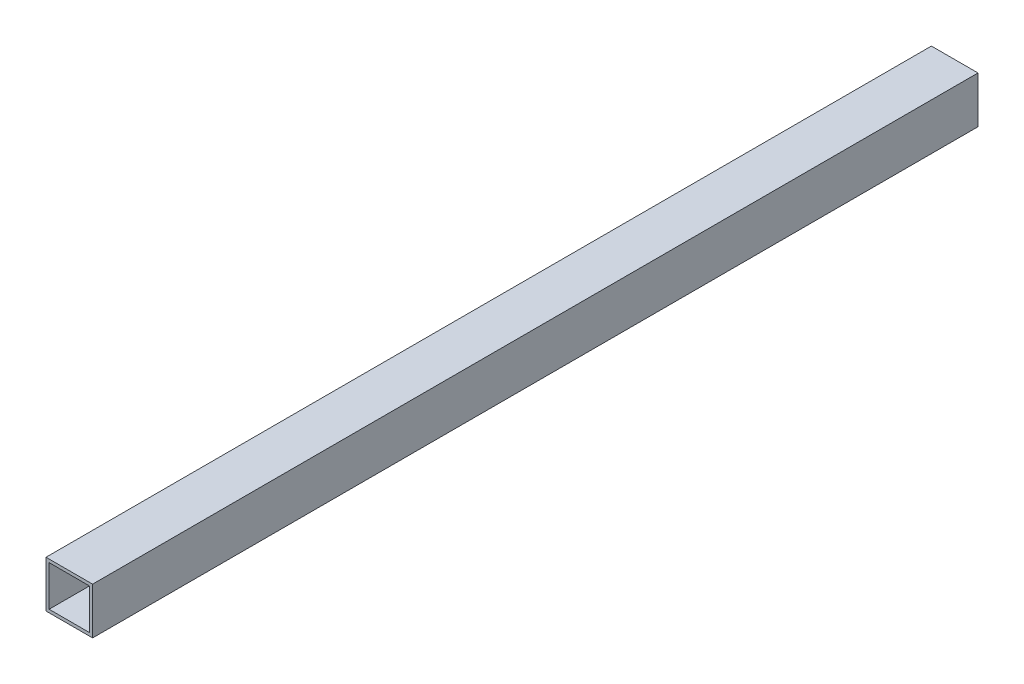
from build123d import *

# Parameters (mm, degrees)
ESBO_O2_W                = 30
ESBO_O2_H                = 30
RESSALTO_EXTRUS_O1_DEPTH = 570
CASCA2_T                 = -2


with BuildPart() as part:
    # Esboço2 → Ressalto-extrusão1 (new body)
    with BuildSketch(Plane.XY):
        with Locations((-79.205213928, 44.662246879)):
            Rectangle(ESBO_O2_W, ESBO_O2_H)
    extrude(amount=RESSALTO_EXTRUS_O1_DEPTH)

    # Casca2
    casca2_openings = [part.faces().sort_by_distance(p)[0] for p in [
        (-79.205213928, 44.662246879, 570),
        (-79.205213928, 44.662246879, 0),
    ]]
    offset(amount=CASCA2_T, openings=casca2_openings, kind=Kind.INTERSECTION)


solid = part.part
